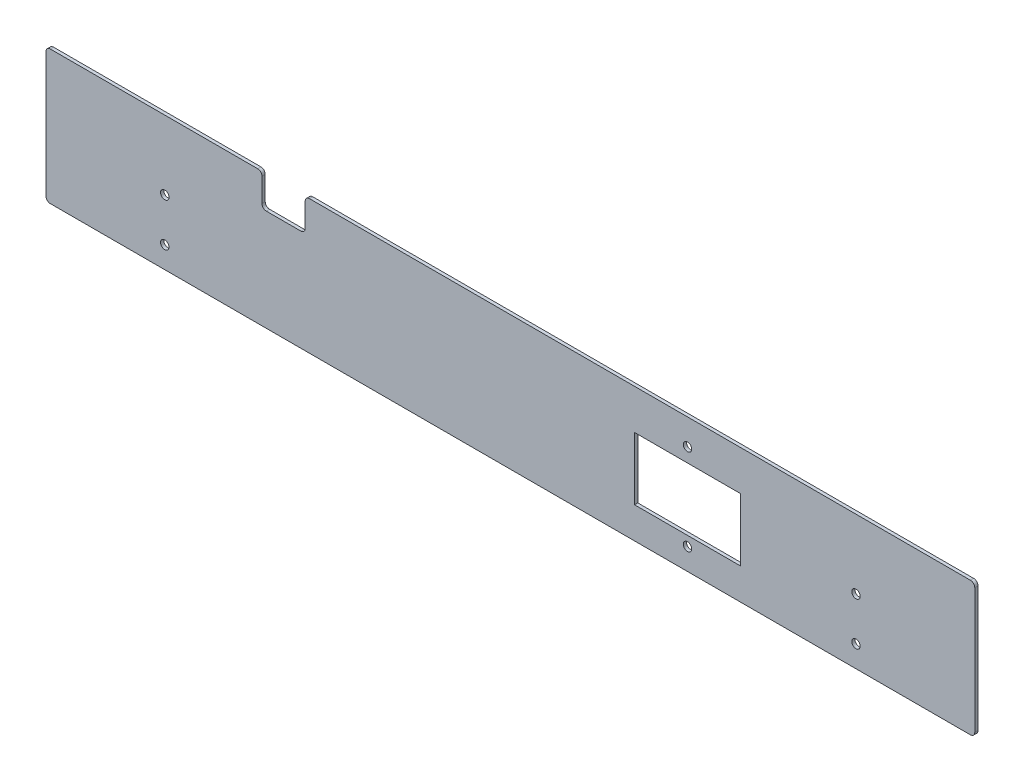
from build123d import *

# Parameters (mm, degrees)
SKETCH1_R           = 1.95
SKETCH1_W           = 49
SKETCH1_H           = 29
BOSS_EXTRUDE1_DEPTH = 1.5
FILLET1_R           = 2
SKETCH3_R           = 1.95
CUT_EXTRUDE1_DEPTH  = 10


with BuildPart() as part:
    # Sketch1 → Boss-Extrude1 (new body)
    with BuildSketch(Plane.XY):
        Polygon((-231.924811832, 29.703517588), (78.075188168, 29.703517588), (78.075188168, -32.296482412), (-351.924811832, -32.296482412), (-351.924811832, 29.703517588), (-251.924811832, 29.703517588), (-251.924811832, 14.703517588), (-231.924811832, 14.703517588), align=None)
        with Locations((-54.924811832, 17.703517588)):
            Circle(SKETCH1_R, mode=Mode.SUBTRACT)
        with Locations((-54.924811832, -22.296482412)):
            Circle(SKETCH1_R, mode=Mode.SUBTRACT)
        with Locations((-54.924811832, -3.296482412)):
            Rectangle(SKETCH1_W, SKETCH1_H, mode=Mode.SUBTRACT)
    extrude(amount=BOSS_EXTRUDE1_DEPTH)

    # Fillet1
    fillet1_edges = [part.edges().sort_by_distance(p)[0] for p in [
        (-351.924811832, 29.703517588, 0.75),
        (-251.924811832, 29.703517588, 0.75),
        (-251.924811832, 14.703517588, 0.75),
        (-231.924811832, 14.703517588, 0.75),
        (-231.924811832, 29.703517588, 0.75),
        (78.075188168, 29.703517588, 0.75),
        (78.075188168, -32.296482412, 0.75),
        (-351.924811832, -32.296482412, 0.75),
    ]]
    fillet(fillet1_edges, radius=FILLET1_R)

    # Sketch3 → Cut-Extrude1 (cut)
    with BuildSketch(Plane(origin=(0, 0, 0), x_dir=(-1, 0, 0), z_dir=(0, 0, -1))):
        with Locations((-23.075188168, -22.296482412)):
            Circle(SKETCH3_R)
        with Locations((-23.075188168, -2.296482412)):
            Circle(SKETCH3_R)
        with Locations((296.924811832, -22.296482412)):
            Circle(SKETCH3_R)
        with Locations((296.924811832, -2.296482412)):
            Circle(SKETCH3_R)
    extrude(amount=-CUT_EXTRUDE1_DEPTH, mode=Mode.SUBTRACT)


solid = part.part
